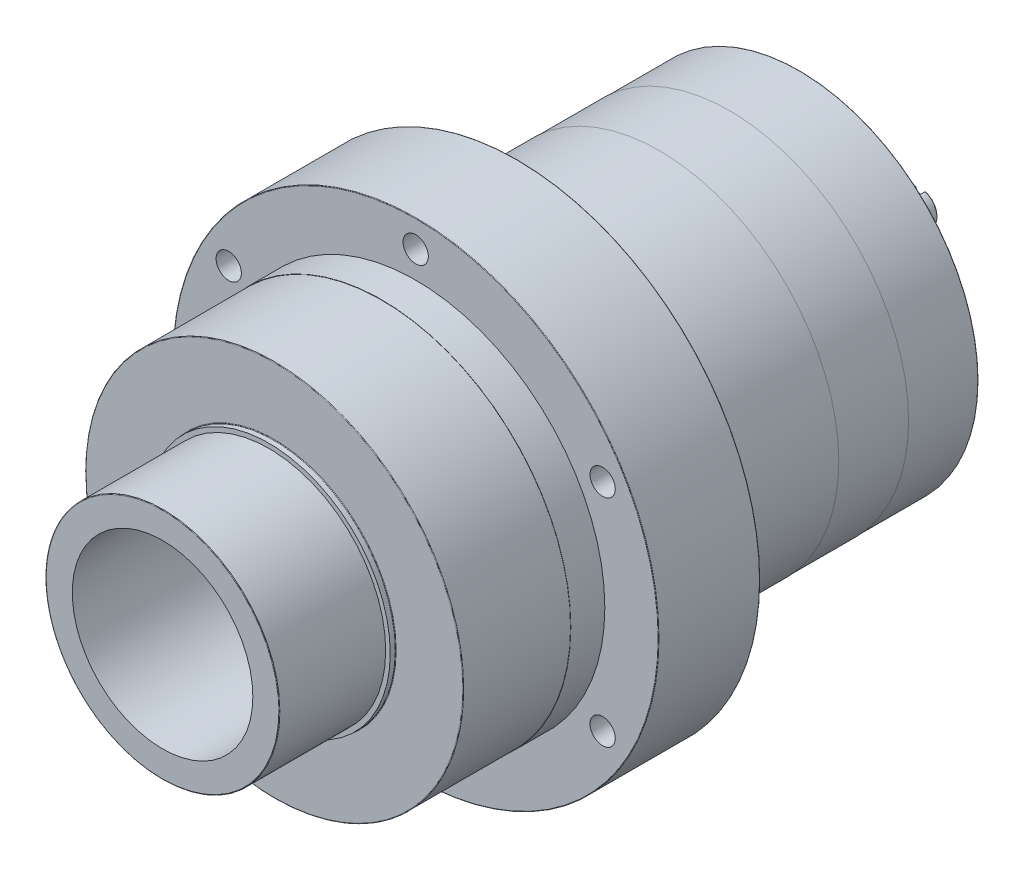
from build123d import *

# Parameters (mm, degrees)
SKETCH1_R                 = 57.15
EXTRUDE_E_DEPTH           = 52.578
SKETCH2_R                 = 57.15
SKETCH2_R_2               = 55.0037
FROM_DRAWING_DEPTH        = 50.0126
SKETCH3_R                 = 88.9
EXTRUDE_C_DEPTH           = 66.548
SKETCH4_R                 = 89.027
SKETCH4_R_2               = 88.9
BOSS_EXTRUDE3_DEPTH       = 16.002
SKETCH5_R                 = 114.3
EXTRUDE_B_DEPTH           = 47.752
CUT_EXTRUDE_START         = -119.38
SKETCH6_R                 = 42.4942
CUT_EXTRUDE_F_DEPTH       = 119.38
SKETCH8_R                 = 84.201
EXTRUDE_D_DEPTH           = 132.842
BOSS_EXTRUDE6_START       = 32.9565
SKETCH9_R                 = 84.328
BOSS_EXTRUDE6_DEPTH       = 32.9565
SKETCH10_R                = 84.455
BOSS_EXTRUDE7_DEPTH       = 66.929
SKETCH11_R                = 27.813
FROM_DRAWING_2_DEPTH      = 7.9248
SKETCH12_R                = 24.9936
EXTRUDE_Q_DEPTH           = 17.526
SKETCH13_R                = 7.9375
EXTRUDE_R_DEPTH           = 31.6992
HOLE_WIZARD_S_D           = 11.90498
HOLE_WIZARD_S_CBORE_D     = 18.25752
HOLE_WIZARD_S_CBORE_DEPTH = 11.1125
CIRPATTERN1_COUNT         = 6
SKETCH16_R                = 19.05
SKETCH16_R_2              = 7.9375
FROM_DRAWING_3_DEPTH      = 14.224
CUT_EXTRUDE_T_REACH       = 111.106
CUT_EXTRUDE_T_END_RADIUS  = 7.9375
CHAMFER1_SIZE             = 0.381
FILLET1_R                 = 0.254


with BuildPart() as part:
    # Sketch1 → Extrude E (new body)
    with BuildSketch(Plane.XY):
        Circle(SKETCH1_R)
    extrude(amount=-EXTRUDE_E_DEPTH)

    # Sketch2 → from drawing (cut)
    with BuildSketch(Plane.XY):
        Circle(SKETCH2_R)
        Circle(SKETCH2_R_2, mode=Mode.SUBTRACT)
    extrude(amount=-FROM_DRAWING_DEPTH, mode=Mode.SUBTRACT)

    # Sketch3 → Extrude C (add)
    with BuildSketch(Plane(origin=(0, 0, -52.578), x_dir=(-1, 0, 0), z_dir=(0, 0, -1))):
        with Locations(Location((0, 0, 0), (0, 0, 180))):  # turned: the seam where the file's is
            Circle(SKETCH3_R)
    extrude(amount=EXTRUDE_C_DEPTH)

    # Sketch4 → Boss-Extrude3 (add)
    with BuildSketch(Plane.XY.offset(-103.124)):
        Circle(SKETCH4_R)
        Circle(SKETCH4_R_2, mode=Mode.SUBTRACT)
    extrude(amount=-BOSS_EXTRUDE3_DEPTH)

    # Sketch5 → Extrude B (add)
    with BuildSketch(Plane.XY.offset(-119.126)):
        Circle(SKETCH5_R)
    extrude(amount=-EXTRUDE_B_DEPTH)

    # Sketch6 → Cut-Extrude F (cut)
    with BuildSketch(Plane.XY.offset(CUT_EXTRUDE_START)):
        Circle(SKETCH6_R)
    extrude(amount=CUT_EXTRUDE_F_DEPTH, mode=Mode.SUBTRACT)

    # Sketch8 → Extrude D (add)
    with BuildSketch(Plane(origin=(0, 0, -166.878), x_dir=(-1, 0, 0), z_dir=(0, 0, -1))):
        with Locations(Location((0, 0, 0), (0, 0, 180))):  # turned: the seam where the file's is
            Circle(SKETCH8_R)
    extrude(amount=EXTRUDE_D_DEPTH)

    # Sketch9 → Boss-Extrude6 (add)
    with BuildSketch(Plane.XY.offset(-299.72).offset(BOSS_EXTRUDE6_START)):
        Circle(SKETCH9_R)
    extrude(amount=BOSS_EXTRUDE6_DEPTH)

    # Sketch10 → Boss-Extrude7 (add)
    with BuildSketch(Plane.XY.offset(-233.807)):
        Circle(SKETCH10_R)
    extrude(amount=BOSS_EXTRUDE7_DEPTH)

    # Sketch11 → from drawing 2 (add)
    with BuildSketch(Plane(origin=(0, 0, -299.72), x_dir=(-1, 0, 0), z_dir=(0, 0, -1))):
        with Locations(Location((0, 0, 0), (0, 0, 180))):  # turned: the seam where the file's is
            Circle(SKETCH11_R)
    extrude(amount=FROM_DRAWING_2_DEPTH)

    # Sketch12 → Extrude Q (add)
    with BuildSketch(Plane(origin=(0, 0, -307.6448), x_dir=(-1, 0, 0), z_dir=(0, 0, -1))):
        with Locations(Location((0, 0, 0), (0, 0, 180))):  # turned: the seam where the file's is
            Circle(SKETCH12_R)
    extrude(amount=EXTRUDE_Q_DEPTH)

    # Sketch13 → Extrude R (add)
    with BuildSketch(Plane(origin=(0, 0, -325.1708), x_dir=(-1, 0, 0), z_dir=(0, 0, -1))):
        with Locations(Location((0, 0, 0), (0, 0, 180))):  # turned: the seam where the file's is
            Circle(SKETCH13_R)
    extrude(amount=EXTRUDE_R_DEPTH)

    # Hole Wizard S (through all)
    with Locations(Plane(origin=(0, 0, -166.878), x_dir=(-1, 0, 0), z_dir=(0, 0, -1))):
        with Locations((0, -101.6)):
            hole_wizard_s = CounterBoreHole(HOLE_WIZARD_S_D / 2, HOLE_WIZARD_S_CBORE_D / 2, HOLE_WIZARD_S_CBORE_DEPTH)

    # CirPattern1: Hole Wizard S ×6 about axis
    cirpattern1_axis = Axis((0, 0, 0), (0, 0, 1))
    for i in range(1, CIRPATTERN1_COUNT):
        add(hole_wizard_s.rotate(cirpattern1_axis, i * 360 / CIRPATTERN1_COUNT), mode=Mode.SUBTRACT)

    # Sketch16 → from drawing 3 (cut)
    with BuildSketch(Plane(origin=(0, 0, -325.1708), x_dir=(-1, 0, 0), z_dir=(0, 0, -1))):
        Circle(SKETCH16_R)
        with Locations(Location((0, 0, 0), (0, 0, 180))):  # turned: the seam where the file's is
            Circle(SKETCH16_R_2, mode=Mode.SUBTRACT)
    extrude(amount=-FROM_DRAWING_3_DEPTH, mode=Mode.SUBTRACT)

    # Cut-Extrude T: up to this cylinder (the profile starts inside it)
    cut_extrude_t_end = Plane(origin=(0, 0, -342.5825), z_dir=(0, 0, 1)) * Cylinder(CUT_EXTRUDE_T_END_RADIUS, 239.087, mode=Mode.PRIVATE)
    # Sketch17 → Cut-Extrude T (cut, up to the surface)
    with BuildSketch(Plane.XZ.offset(-5.1943), mode=Mode.PRIVATE) as cut_extrude_t_sk1:
        with BuildLine():
            Line((-2.3876, -356.87), (-2.3876, -328.295))
            ThreePointArc((-2.3876, -328.295), (0, -325.9074), (2.3876, -328.295))
            Line((2.3876, -328.295), (2.3876, -356.87))
            ThreePointArc((2.3876, -356.87), (0, -359.2576), (-2.3876, -356.87))
        make_face()
    cut_extrude_t_tool1 = extrude(cut_extrude_t_sk1.sketch, amount=-CUT_EXTRUDE_T_REACH, mode=Mode.PRIVATE) & cut_extrude_t_end
    add(cut_extrude_t_tool1.solids().sort_by_distance((0, 5.1943, -342.5825))[0], mode=Mode.SUBTRACT)

    # Chamfer1
    chamfer1_edges = [part.edges().sort_by_distance(p)[0] for p in [
        (-4.693204196, -6.401385836, -356.87),
    ]]
    chamfer(chamfer1_edges, length=CHAMFER1_SIZE)

    # Fillet1
    fillet1_edges = [part.edges().sort_by_distance(p)[0] for p in [
        (-83.423801024, -58.705738065, -166.878),
        (-55.0037, 0, 0),
        (-88.9, 0, -52.578),
        (-114.3, 0, -119.126),
        (-114.3, 0, -166.878),
        (-84.201, 0, -299.72),
        (-57.15, 0, -52.578),
        (-84.455, 0, -166.878),
        (-27.813, 0, -299.72),
        (-27.813, 0, -307.6448),
        (-24.9936, 0, -307.6448),
        (-24.9936, 0, -325.1708),
        (9.12876, -101.6, -166.878),
        (92.552561024, -42.894261935, -166.878),
        (83.423801024, 58.705738065, -166.878),
        (-9.12876, 101.6, -166.878),
        (-92.552561024, 42.894261935, -166.878),
    ]]
    fillet(fillet1_edges, radius=FILLET1_R)


solid = part.part
